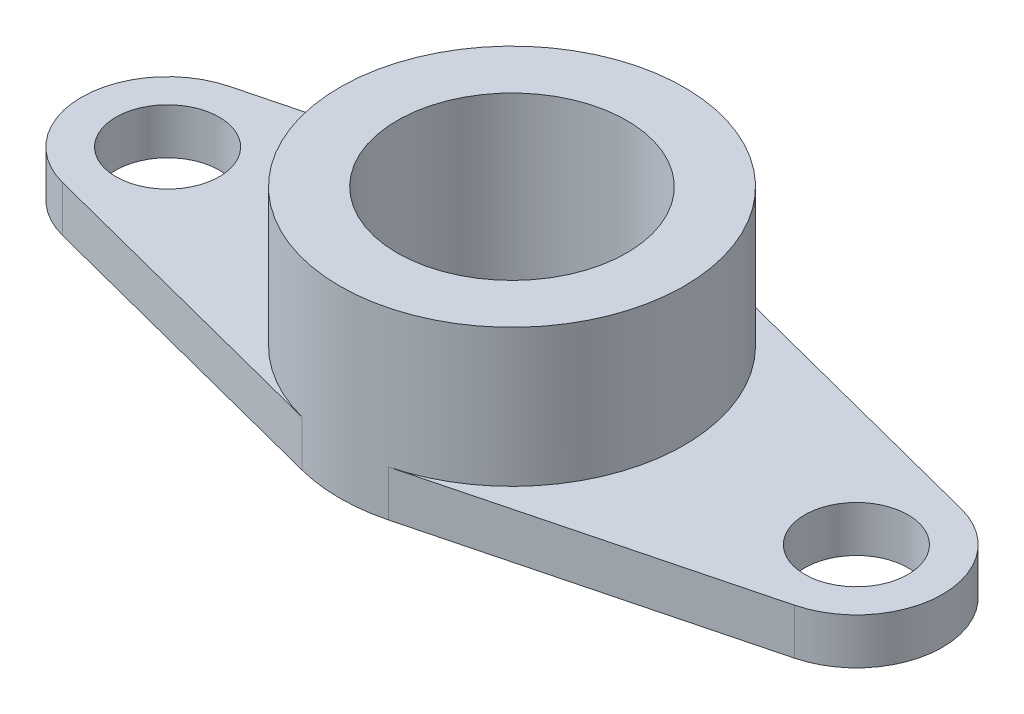
from build123d import *

# Parameters (mm, degrees)
SKETCH2_R           = 2.25
SKETCH2_R_2         = 5
BOSS_EXTRUDE2_DEPTH = 2
SKETCH3_R           = 7.5
SKETCH3_R_2         = 5
BOSS_EXTRUDE3_DEPTH = 6


with BuildPart() as part:
    # Sketch2 → Boss-Extrude2 (new body)
    with BuildSketch(Plane(origin=(0, 0, 0), x_dir=(1, 0, 0), z_dir=(0, 1, 0))):
        with BuildLine():
            Line((-1.875, 7.261843774), (-15.9375, 3.630921887))
            ThreePointArc((-15.9375, 3.630921887), (-18.75, 0), (-15.9375, -3.630921887))
            Line((-15.9375, -3.630921887), (-1.875, -7.261843774))
            ThreePointArc((-1.875, -7.261843774), (0, -7.5), (1.875, -7.261843774))
            Line((1.875, -7.261843774), (15.9375, -3.630921887))
            ThreePointArc((15.9375, -3.630921887), (18.75, 0), (15.9375, 3.630921887))
            Line((15.9375, 3.630921887), (1.875, 7.261843774))
            ThreePointArc((1.875, 7.261843774), (0, 7.5), (-1.875, 7.261843774))
        make_face()
        with Locations((-15, 0)):
            Circle(SKETCH2_R, mode=Mode.SUBTRACT)
        Circle(SKETCH2_R_2, mode=Mode.SUBTRACT)
        with Locations((15, 0)):
            Circle(SKETCH2_R, mode=Mode.SUBTRACT)
    extrude(amount=BOSS_EXTRUDE2_DEPTH)

    # Sketch3 → Boss-Extrude3 (add)
    with BuildSketch(Plane(origin=(0, 2, 0), x_dir=(1, 0, 0), z_dir=(0, 1, 0))):
        Circle(SKETCH3_R)
        Circle(SKETCH3_R_2, mode=Mode.SUBTRACT)
    extrude(amount=BOSS_EXTRUDE3_DEPTH)


solid = part.part
